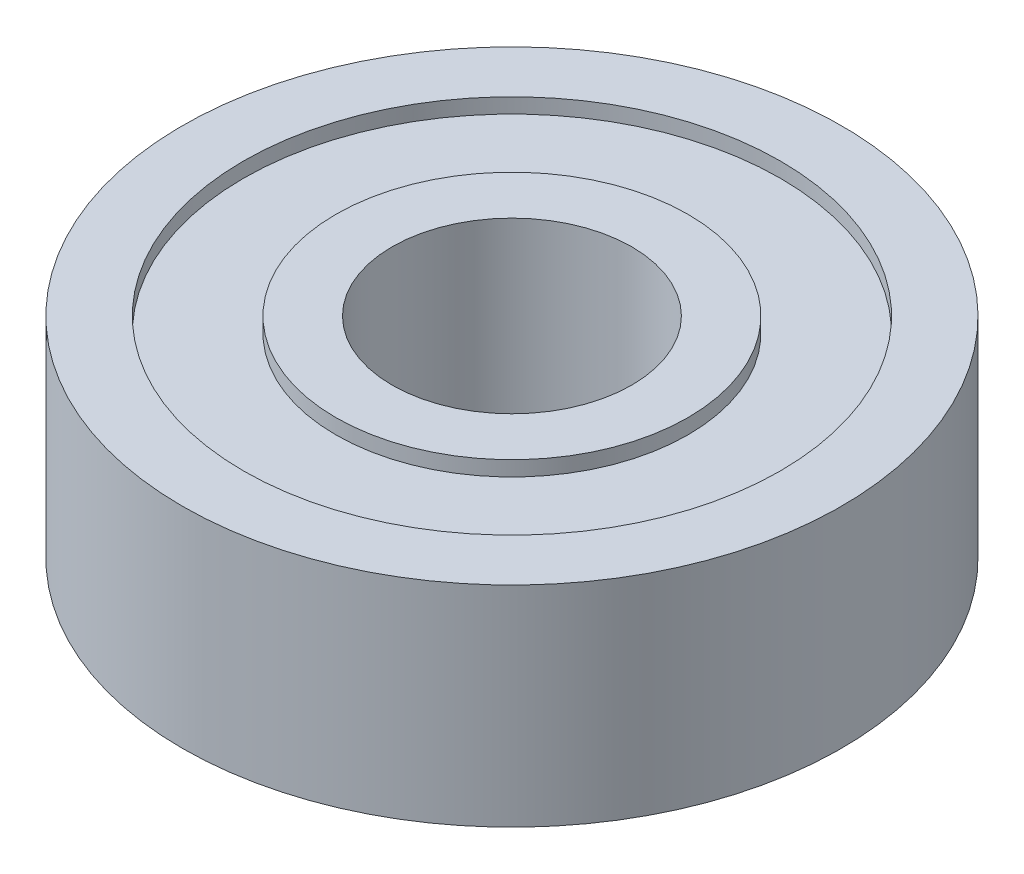
from build123d import *

# Parameters (mm, degrees)
ESQUISSE1_R             = 11
ESQUISSE1_R_2           = 4
BOSS_EXTRU_1_DEPTH      = 7
ESQUISSE2_R             = 8.959660805
ESQUISSE2_R_2           = 5.876621398
ENL_V_MAT_EXTRU_1_DEPTH = 0.5


with BuildPart() as part:
    # Esquisse1 → Boss.-Extru.1 (new body)
    with BuildSketch(Plane(origin=(0, 0, 0), x_dir=(1, 0, 0), z_dir=(0, 1, 0))):
        Circle(ESQUISSE1_R)
        Circle(ESQUISSE1_R_2, mode=Mode.SUBTRACT)
    extrude(amount=BOSS_EXTRU_1_DEPTH)

    # Esquisse2 → Enlèv. mat.-Extru.1 (cut)
    with BuildSketch(Plane(origin=(0, 7, 0), x_dir=(1, 0, 0), z_dir=(0, 1, 0))):
        Circle(ESQUISSE2_R)
        Circle(ESQUISSE2_R_2, mode=Mode.SUBTRACT)
    enl_v_mat_extru_1 = extrude(amount=-ENL_V_MAT_EXTRU_1_DEPTH, mode=Mode.SUBTRACT)

    # Symétrie1: Enlèv. mat.-Extru.1 across plane
    add(enl_v_mat_extru_1.mirror(Plane.ZX.offset(3.5)), mode=Mode.SUBTRACT)


solid = part.part
